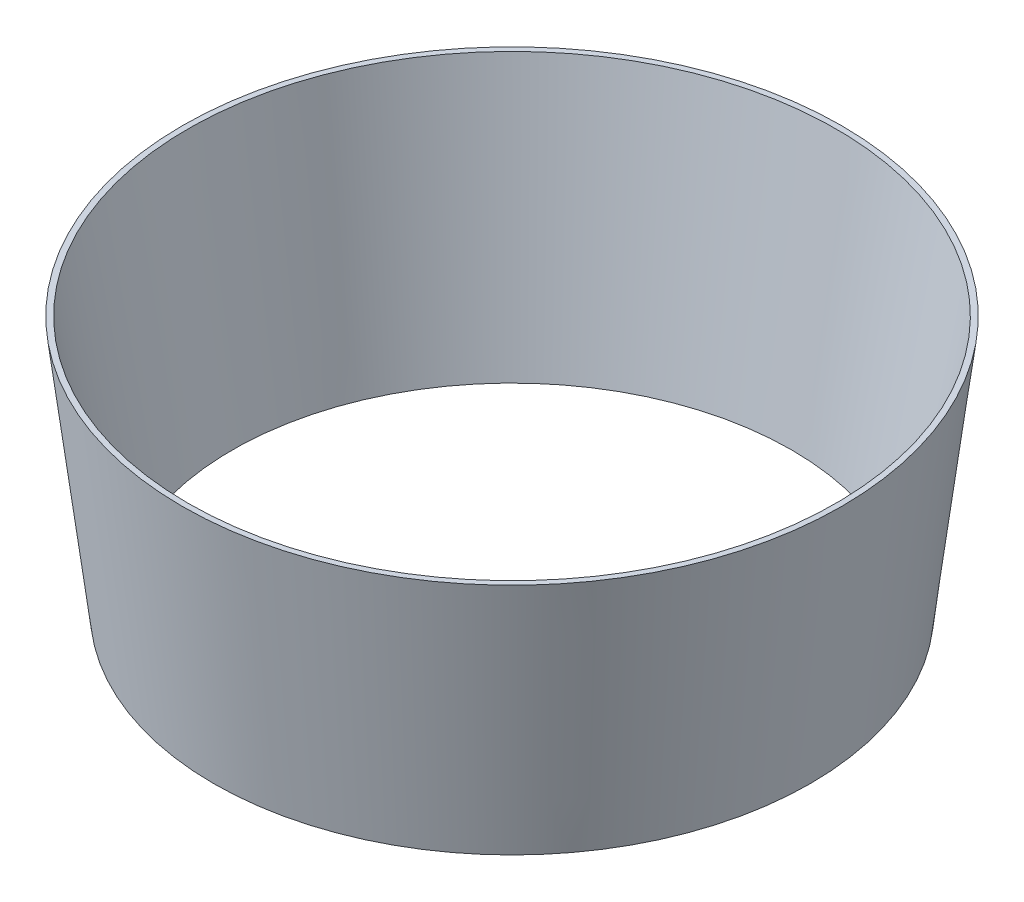
from build123d import *

# Parameters (mm, degrees)
SKETCH_1_R = 802
SKETCH_2_R = 886.455
SKETCH_4_R = 871.455
SKETCH_3_R = 752


with BuildPart() as part:
    # 草图1 → Loft 1 section 0
    with BuildSketch(Plane(origin=(0, 0, 0), x_dir=(1, 0, 0), z_dir=(0, 1, 0))):
        Circle(SKETCH_1_R)
    # 草图2 → Loft 1 section 1
    with BuildSketch(Plane(origin=(0, 687.83, 0), x_dir=(1, 0, 0), z_dir=(0, 1, 0))):
        Circle(SKETCH_2_R)
    loft()

    # 草图4 → Loft 1 2 section 0
    with BuildSketch(Plane(origin=(0, 687.83, 0), x_dir=(1, 0, 0), z_dir=(0, 1, 0))):
        Circle(SKETCH_4_R)
    # 草图3 → Loft 1 2 section 1
    with BuildSketch(Plane.XZ):
        Circle(SKETCH_3_R)
    loft(mode=Mode.SUBTRACT)


solid = part.part
